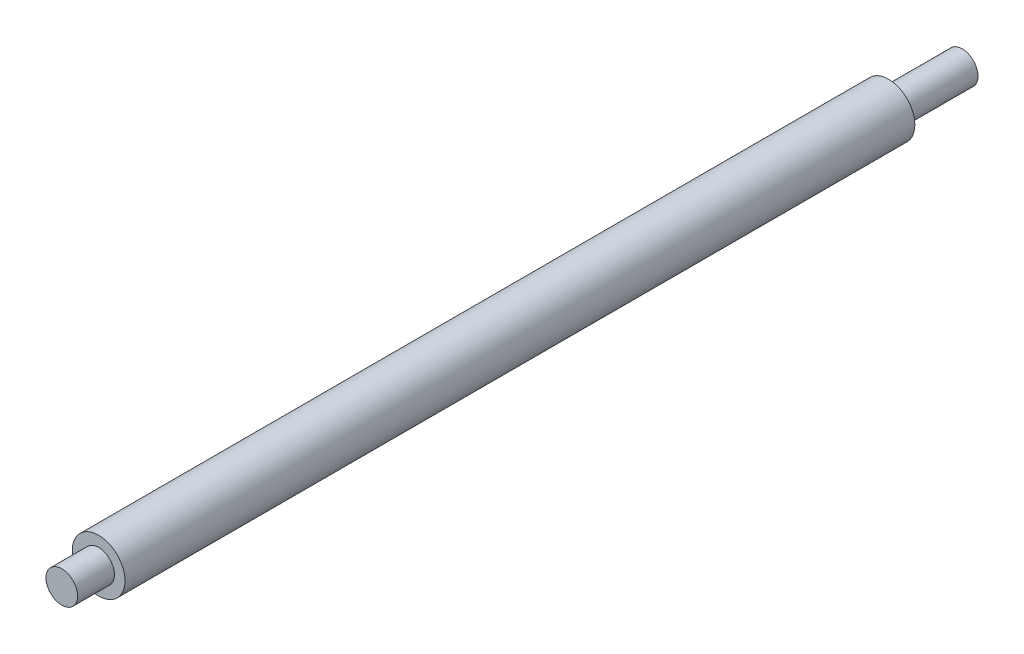
from build123d import *

# Parameters (mm, degrees)
SKETCH1_R           = 25
BOSS_EXTRUDE2_DEPTH = 750
SKETCH2_R           = 15
BOSS_EXTRUDE3_DEPTH = 70
SKETCH3_R           = 15
BOSS_EXTRUDE4_DEPTH = 35


with BuildPart() as part:
    # Sketch1 → Boss-Extrude2 (new body)
    with BuildSketch(Plane.XY):
        Circle(SKETCH1_R)
    extrude(amount=BOSS_EXTRUDE2_DEPTH)

    # Sketch2 → Boss-Extrude3 (add)
    with BuildSketch(Plane(origin=(0, 0, 0), x_dir=(-1, 0, 0), z_dir=(0, 0, -1))):
        Circle(SKETCH2_R)
    extrude(amount=BOSS_EXTRUDE3_DEPTH)

    # Sketch3 → Boss-Extrude4 (add)
    with BuildSketch(Plane.XY.offset(750)):
        Circle(SKETCH3_R)
    extrude(amount=BOSS_EXTRUDE4_DEPTH)


solid = part.part
